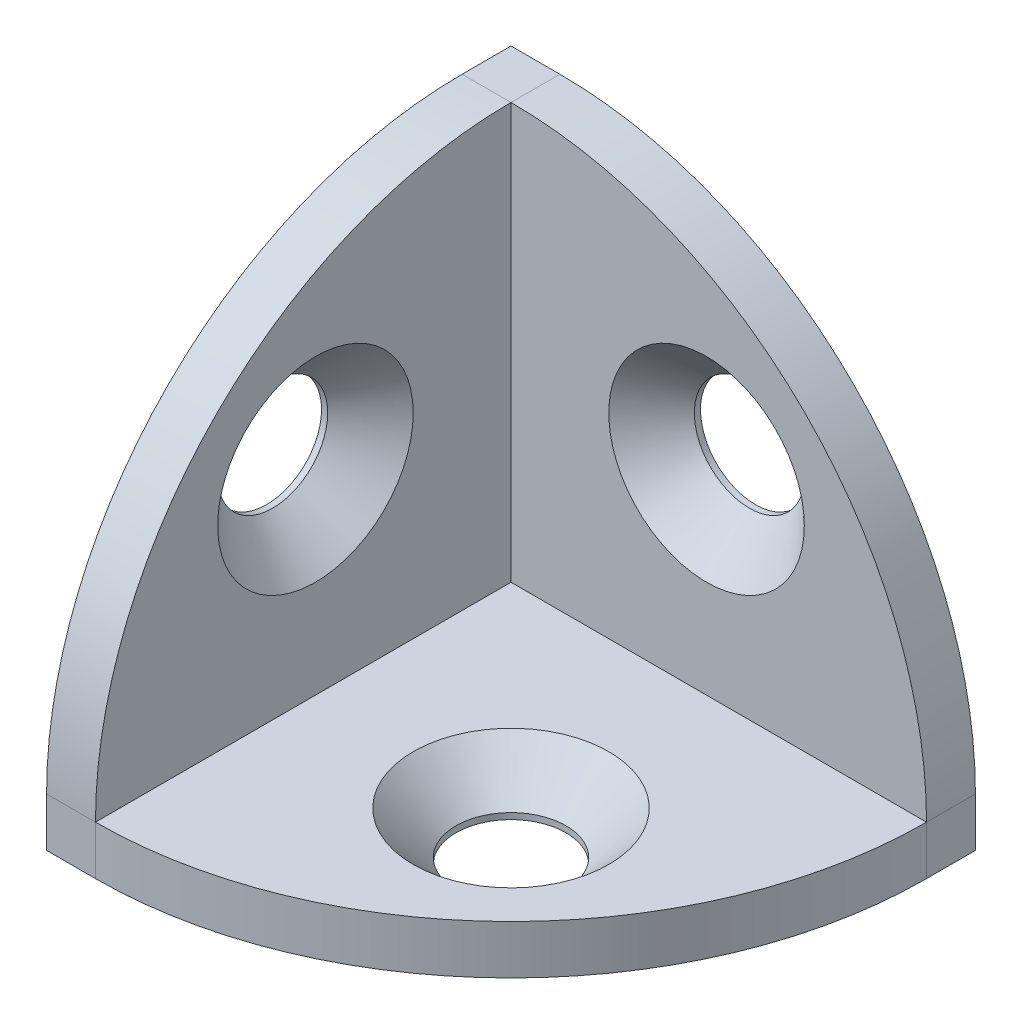
from build123d import *

# Parameters (mm, degrees)
EXTRUDE_1_DEPTH            = 4
SKETCH_4_W                 = 1.5
SKETCH_4_H                 = 8
SKETCH_4_W_2               = 8
SKETCH_4_H_2               = 1.5
EXTRUDE_2_DEPTH            = 1
MIRROR_2_COPY_1_DEPTH      = 4
MIRROR_2_COPY_3_SKETCH_W   = 1.5
MIRROR_2_COPY_3_SKETCH_H   = 8
MIRROR_2_COPY_3_SKETCH_W_2 = 8
MIRROR_2_COPY_3_SKETCH_H_2 = 1.5
MIRROR_2_COPY_3_DEPTH      = 1


with BuildPart() as part:
    # Эскиз1 → Бобышка-Вытянуть1 (new body)
    with BuildSketch(Plane.XY):
        with BuildLine():
            Line((0, 0), (0, 38))
            Line((0, 38), (4, 38))
            ThreePointArc((4, 38), (28.04163056, 28.04163056), (38, 4))
            Line((38, 4), (38, 0))
            Line((38, 0), (0, 0))
        make_face()
    extrude_1 = extrude(amount=EXTRUDE_1_DEPTH)

    # Эскиз3 → Зенковка для винта с полупотайной головкой M81 (revolve, cut)
    with BuildSketch(Plane(origin=(20, 20, 4), x_dir=(0, -1, 0), z_dir=(1, 0, 0))):
        Polygon((0, 0), (0, 11.953872786), (4.5, 9.25), (4.5, 3.5), (8, 0), align=None)
    hole_wizard_m81 = revolve(axis=Axis((20, 20, 10.35), (0, 0, -1)), mode=Mode.SUBTRACT)

    # Эскиз4 → Бобышка-Вытянуть2 (add)
    with BuildSketch(Plane(origin=(0, 0, 0), x_dir=(-1, 0, 0), z_dir=(0, 0, -1))):
        with Locations((-2.25, 20)):
            Rectangle(SKETCH_4_W, SKETCH_4_H)
        with Locations((-20, 2.25)):
            Rectangle(SKETCH_4_W_2, SKETCH_4_H_2)
    extrude_2 = extrude(amount=EXTRUDE_2_DEPTH)

    # Зеркальное отражение1: Бобышка-Вытянуть1, Зенковка для винта с полупотайной головкой M81, Бобышка-Вытянуть2 across plane
    add(extrude_1.mirror(Plane(origin=(0, 0, 0), x_dir=(0, 0.707106781, 0.707106781), z_dir=(0, -0.707106781, 0.707106781))))
    add(hole_wizard_m81.mirror(Plane(origin=(0, 0, 0), x_dir=(0, 0.707106781, 0.707106781), z_dir=(0, -0.707106781, 0.707106781))), mode=Mode.SUBTRACT)
    add(extrude_2.mirror(Plane(origin=(0, 0, 0), x_dir=(0, 0.707106781, 0.707106781), z_dir=(0, -0.707106781, 0.707106781))))

    # Зеркальное отражение2: Бобышка-Вытянуть1, Зенковка для винта с полупотайной головкой M81, Бобышка-Вытянуть2 across plane
    add(extrude_1.mirror(Plane(origin=(0, 0, 0), x_dir=(0.707106781, 0, 0.707106781), z_dir=(-0.707106781, 0, 0.707106781))))
    add(hole_wizard_m81.mirror(Plane(origin=(0, 0, 0), x_dir=(0.707106781, 0, 0.707106781), z_dir=(-0.707106781, 0, 0.707106781))), mode=Mode.SUBTRACT)
    add(extrude_2.mirror(Plane(origin=(0, 0, 0), x_dir=(0.707106781, 0, 0.707106781), z_dir=(-0.707106781, 0, 0.707106781))))

    # Зеркальное отражение2 copy 1 sketch → Зеркальное отражение2 copy 1 (add)
    with BuildSketch(Plane.ZX):
        with BuildLine():
            Line((0, 0), (0, 38))
            Line((0, 38), (4, 38))
            ThreePointArc((4, 38), (28.04163056, 28.04163056), (38, 4))
            Line((38, 4), (38, 0))
            Line((38, 0), (0, 0))
        make_face()
    extrude(amount=MIRROR_2_COPY_1_DEPTH)

    # Зеркальное отражение2 copy 2 sketch → Зеркальное отражение2 copy 2 (revolve, cut)
    with BuildSketch(Plane(origin=(20, 4, 20), x_dir=(-1, 0, 0), z_dir=(0, 0, 1))):
        Polygon((0, 0), (0, 11.953872786), (4.5, 9.25), (4.5, 3.5), (8, 0), align=None)
    revolve(axis=Axis((20, 10.35, 20), (0, -1, 0)), mode=Mode.SUBTRACT)

    # Зеркальное отражение2 copy 3 sketch → Зеркальное отражение2 copy 3 (add)
    with BuildSketch(Plane(origin=(0, 0, 0), x_dir=(0, 0, -1), z_dir=(0, -1, 0))):
        with Locations((-2.25, 20)):
            Rectangle(MIRROR_2_COPY_3_SKETCH_W, MIRROR_2_COPY_3_SKETCH_H)
        with Locations((-20, 2.25)):
            Rectangle(MIRROR_2_COPY_3_SKETCH_W_2, MIRROR_2_COPY_3_SKETCH_H_2)
    extrude(amount=MIRROR_2_COPY_3_DEPTH)


solid = part.part
